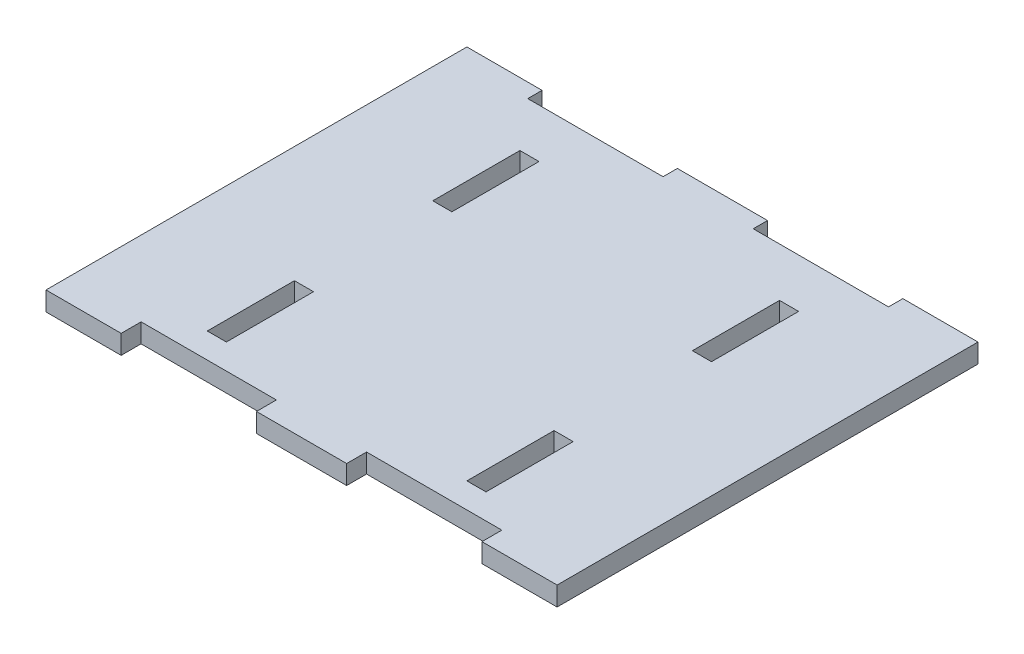
from build123d import *

# Parameters (mm, degrees)
SKETCH1_W           = 85
SKETCH1_H           = 70
BOSS_EXTRUDE1_DEPTH = 3.175
SKETCH2_W           = 3.175
SKETCH2_H           = 14.492
SKETCH2_W_2         = 22.5
SKETCH2_H_2         = 2.38125
SKETCH2_H_3         = 3.313043478
CUT_EXTRUDE1_DEPTH  = 4.175


with BuildPart() as part:
    # Sketch1 → Boss-Extrude1 (new body)
    with BuildSketch(Plane(origin=(0, 0, 0), x_dir=(1, 0, 0), z_dir=(0, 1, 0))):
        with Locations((42.5, 35)):
            Rectangle(SKETCH1_W, SKETCH1_H)
    extrude(amount=BOSS_EXTRUDE1_DEPTH)

    # Sketch2 → Cut-Extrude1 (cut, through all)
    with BuildSketch(Plane.XZ):
        with Locations((20.9125, -14.746)):
            Rectangle(SKETCH2_W, SKETCH2_H)
        with Locations((20.9125, -52.246)):
            Rectangle(SKETCH2_W, SKETCH2_H)
        with Locations((64.0875, -14.746)):
            Rectangle(SKETCH2_W, SKETCH2_H)
        with Locations((64.0875, -52.246)):
            Rectangle(SKETCH2_W, SKETCH2_H)
        with Locations((61.25, -68.809375)):
            Rectangle(SKETCH2_W_2, SKETCH2_H_2)
        with Locations((23.75, -68.809375)):
            Rectangle(SKETCH2_W_2, SKETCH2_H_2)
        with Locations((61.25, -1.656521739)):
            Rectangle(SKETCH2_W_2, SKETCH2_H_3)
        with Locations((23.75, -1.656521739)):
            Rectangle(SKETCH2_W_2, SKETCH2_H_3)
    extrude(amount=-CUT_EXTRUDE1_DEPTH, mode=Mode.SUBTRACT)


solid = part.part
